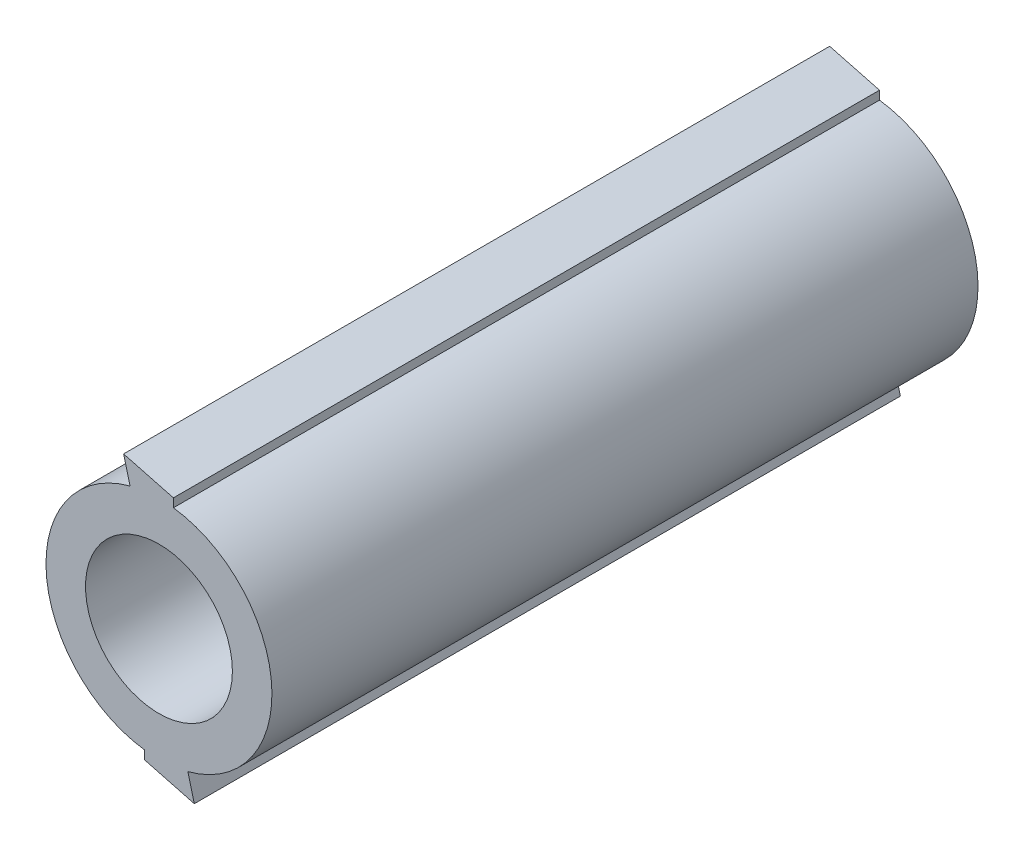
from build123d import *

# Parameters (mm, degrees)
SKETCH1_R           = 40
SKETCH1_R_2         = 26
BOSS_EXTRUDE1_DEPTH = 200
SKETCH3_R           = 4
CUT_EXTRUDE1_DEPTH  = 10
BOSS_EXTRUDE2_DEPTH = 200
SCALE3_SCALE_X      = 0.8
SCALE3_SCALE_Y      = 0.8
SCALE3_SCALE_Z      = 1


with BuildPart() as part:
    # Sketch1 → Boss-Extrude1 (new body)
    with BuildSketch(Plane.XY):
        Circle(SKETCH1_R)
        Circle(SKETCH1_R_2, mode=Mode.SUBTRACT)
    extrude(amount=BOSS_EXTRUDE1_DEPTH)

    # Sketch3 → Cut-Extrude1 (cut)
    with BuildSketch(Plane(origin=(0, 0, 0), x_dir=(-1, 0, 0), z_dir=(0, 0, -1))):
        with Locations((0, 33)):
            Circle(SKETCH3_R)
        with Locations((28.578838325, 16.5)):
            Circle(SKETCH3_R)
        with Locations((28.578838325, -16.5)):
            Circle(SKETCH3_R)
        with Locations((0, -33)):
            Circle(SKETCH3_R)
        with Locations((-28.578838325, -16.5)):
            Circle(SKETCH3_R)
        with Locations((-28.578838325, 16.5)):
            Circle(SKETCH3_R)
    extrude(amount=-CUT_EXTRUDE1_DEPTH, mode=Mode.SUBTRACT)

    # Sketch4 → Boss-Extrude2 (add)
    with BuildSketch(Plane.XY.offset(200)):
        with BuildLine():
            Line((-12.524283468, 47.372379332), (-10.223904872, 38.671330067))
            ThreePointArc((-10.223904872, 38.671330067), (-2.601743611, 39.915296945), (5.117405442, 39.671301485))
            Line((5.117405442, 39.671301485), (5.117405442, 42.72725721))
            Line((5.117405442, 42.72725721), (-12.524283468, 47.372379332))
        make_face()
        with BuildLine():
            ThreePointArc((10.223904872, -38.671330067), (2.601743611, -39.915296945), (-5.117405442, -39.671301485))
            Line((-5.117405442, -39.671301485), (-5.117405442, -42.72725721))
            Line((-5.117405442, -42.72725721), (12.524283468, -47.372379332))
            Line((12.524283468, -47.372379332), (10.223904872, -38.671330067))
        make_face()
    extrude(amount=-BOSS_EXTRUDE2_DEPTH)


with BuildPart() as part_1:
    # Scale3: scaled about (0, 0, 100.467831969)
    add(part.part.scale((SCALE3_SCALE_X, SCALE3_SCALE_Y, SCALE3_SCALE_Z), about=(0, 0, 100.467831969)))


solid = part_1.part
